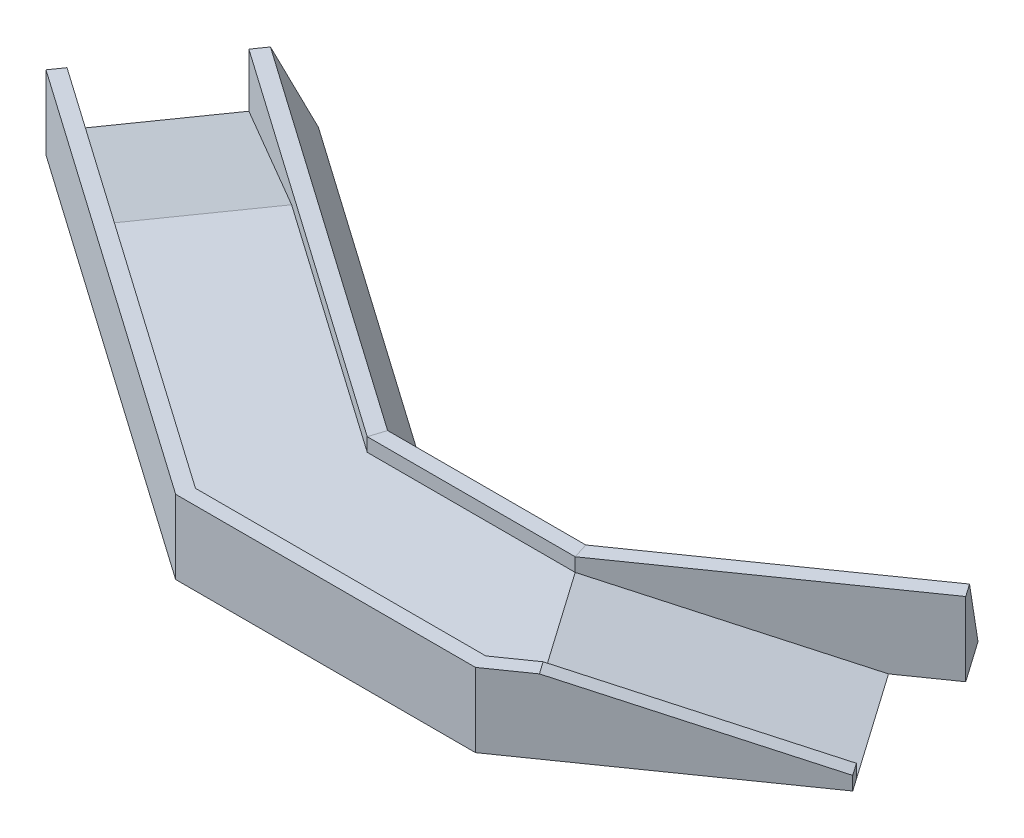
from build123d import *

# Parameters (mm, degrees)
EXTRUDE_1_DEPTH      = 600
EXTRUDE_2_DEPTH      = 135
EXTRUDE_2_DEPTH_BACK = 600
CUT_EXTRUDE_1_DEPTH  = 1300
CUT_EXTRUDE_2_DEPTH  = 8114.690330729
CUT_EXTRUDE_3_DEPTH  = 1300


with BuildPart() as part:
    # Sketch 1 → Extrude 1 (new body)
    with BuildSketch(Plane(origin=(0, 0, 0), x_dir=(1, 0, 0), z_dir=(0, 1, 0))):
        Polygon((2815.872516171, -1064.897657576), (2070.223148915, 0), (0, 0), (-3929.563752899, 2751.510161656), (-4675.213120155, 1686.61250408), (-409.888425543, -1300), (2480.111574457, -1300), align=None)
        Polygon((4649.953943334, 219.339983414), (3904.304576078, 1284.23764099), (2070.223148915, 0), (2815.872516171, -1064.897657576), align=None)
    extrude(amount=EXTRUDE_1_DEPTH)

    # Sketch 2 → Extrude 2 (add, two sides)
    with BuildSketch(Plane(origin=(0, 600, 0), x_dir=(1, 0, 0), z_dir=(0, 1, 0))) as extrude_2_sk:
        Polygon((4649.953943334, 219.339983414), (4735.990408787, 96.467176771), (2527.406392789, -1450), (-457.183243875, -1450), (-4761.249585608, 1563.739697437), (-4675.213120155, 1686.61250408), (-409.888425543, -1300), (2480.111574457, -1300), align=None)
    extrude(amount=EXTRUDE_2_DEPTH)
    extrude(extrude_2_sk.sketch, amount=-EXTRUDE_2_DEPTH_BACK)

    # Sweep 1: sweep along a path in Sketch 4
    with BuildLine(Plane(origin=(0, 600, 0), x_dir=(1, 0, 0), z_dir=(0, 1, 0))) as sweep_1_path:
        Line((-3929.563752899, 2751.510161656), (0, 0))
        Line((0, 0), (2070.223148915, 0))
        Line((2070.223148915, 0), (4356.476504525, 1600.851833856))
    # Sketch 3 → Sweep 1 (sweep)
    with BuildSketch(Plane(origin=(-3929.563752899, 0, -2751.510161656), x_dir=(-0.5735764363510467, 0, 0.8191520442889915), z_dir=(-0.8191520442889914, 0, -0.5735764363510466))):
        Polygon((0, 0), (0, 735), (-154.263871256, 735), (-497, 0), align=None)
    sweep(path=sweep_1_path.line, transition=Transition.RIGHT)

    # Sketch 5 → Cut-Extrude 1 (cut)
    with BuildSketch(Plane(origin=(681.082565403, 0, 972.686708208), x_dir=(0.8191520442889921, 2.43053022929219e-15, -0.5735764363510456), z_dir=(0.5735764363510456, -3.4711569022901e-15, 0.8191520442889921))):
        Polygon((3934.827524568, 0), (1695.597040027, 600), (3934.827524568, 600), align=None)
    extrude(amount=CUT_EXTRUDE_1_DEPTH, mode=Mode.SUBTRACT)

    # Sketch 7 → Cut-Extrude 2 (cut, through all)
    with BuildSketch(Plane(origin=(1426.73193266, 0, 2037.584365783), x_dir=(-0.8191520442889908, 0, 0.5735764363510475), z_dir=(-0.5735764363510475, 0, -0.8191520442889908))):
        Polygon((-3934.827524568, 135), (-1695.597040026, 735), (-3934.827524568, 735), align=None)
    extrude(amount=-CUT_EXTRUDE_2_DEPTH, mode=Mode.SUBTRACT)

    # Sketch 8 → Cut-Extrude 3 (cut)
    with BuildSketch(Plane(origin=(-745.649367256, 0, 1064.897657576), x_dir=(-0.8191520442889912, 0, -0.5735764363510469), z_dir=(0.5735764363510469, 0, -0.8191520442889914))):
        Polygon((4797.111574457, 200), (2479.771981715, 735), (4797.111574457, 735), align=None)
    extrude(amount=CUT_EXTRUDE_3_DEPTH, mode=Mode.SUBTRACT)


solid = part.part
